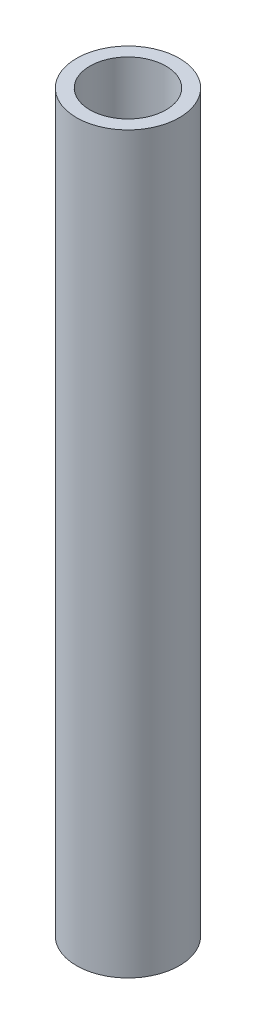
from build123d import *

# Parameters (mm, degrees)
SKETCH1_R                    = 19.05
BOSS_EXTRUDE1_DEPTH          = 272.1102
SKETCH2_R                    = 12.7
CUT_EXTRUDE1_DEPTH           = 273.1102
F_1_1_4_7_TAPPED_HOLE1_D     = 28.17876
F_1_1_4_7_TAPPED_HOLE1_DEPTH = 49.022
F_1_1_4_7_TAPPED_HOLE1_TIP   = 8.465753589
F_1_1_4_7_TAPPED_HOLE2_D     = 28.17876
F_1_1_4_7_TAPPED_HOLE2_DEPTH = 49.022
F_1_1_4_7_TAPPED_HOLE2_TIP   = 8.465753589


with BuildPart() as part:
    # Sketch1 → Boss-Extrude1 (new body)
    with BuildSketch(Plane(origin=(0, 0, 0), x_dir=(1, 0, 0), z_dir=(0, 1, 0))):
        Circle(SKETCH1_R)
    extrude(amount=BOSS_EXTRUDE1_DEPTH)

    # Sketch2 → Cut-Extrude1 (cut, through all)
    with BuildSketch(Plane(origin=(0, 272.1102, 0), x_dir=(1, 0, 0), z_dir=(0, 1, 0))):
        Circle(SKETCH2_R)
    extrude(amount=-CUT_EXTRUDE1_DEPTH, mode=Mode.SUBTRACT)

    # 1-1/4-7 Tapped Hole1
    with Locations(Plane(origin=(0, 272.1102, 0), x_dir=(1, 0, 0), z_dir=(0, 1, 0))):
        with Locations((0, 0)):
            Hole(F_1_1_4_7_TAPPED_HOLE1_D / 2, depth=F_1_1_4_7_TAPPED_HOLE1_DEPTH)
            with Locations((0, 0, -(F_1_1_4_7_TAPPED_HOLE1_DEPTH + F_1_1_4_7_TAPPED_HOLE1_TIP / 2))):  # 118° drill point
                Cone(0, F_1_1_4_7_TAPPED_HOLE1_D / 2, F_1_1_4_7_TAPPED_HOLE1_TIP, mode=Mode.SUBTRACT)

    # 1-1/4-7 Tapped Hole2
    with Locations(Plane(origin=(0, 0, 0), x_dir=(-1, 0, 0), z_dir=(0, -1, 0))):
        with Locations((0, 0)):
            Hole(F_1_1_4_7_TAPPED_HOLE2_D / 2, depth=F_1_1_4_7_TAPPED_HOLE2_DEPTH)
            with Locations((0, 0, -(F_1_1_4_7_TAPPED_HOLE2_DEPTH + F_1_1_4_7_TAPPED_HOLE2_TIP / 2))):  # 118° drill point
                Cone(0, F_1_1_4_7_TAPPED_HOLE2_D / 2, F_1_1_4_7_TAPPED_HOLE2_TIP, mode=Mode.SUBTRACT)


solid = part.part
